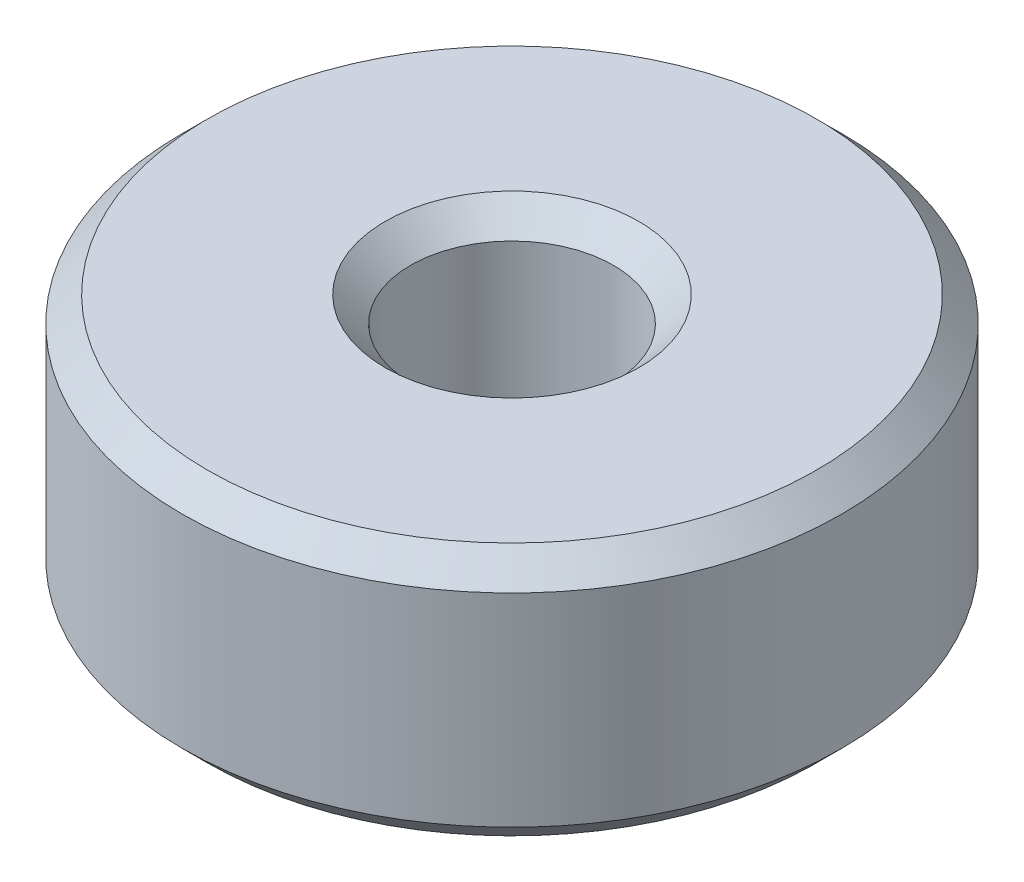
from build123d import *

# Parameters (mm, degrees)
SKETCH_1_R      = 6.5
SKETCH_1_R_2    = 2
EXTRUDE_1_DEPTH = 5
CHAMFER_1_SIZE  = 0.5


with BuildPart() as part:
    # 草图1 → 凸台-拉伸1 (new body)
    with BuildSketch(Plane(origin=(0, 0, 0), x_dir=(1, 0, 0), z_dir=(0, 1, 0))):
        Circle(SKETCH_1_R)
        Circle(SKETCH_1_R_2, mode=Mode.SUBTRACT)
    extrude(amount=EXTRUDE_1_DEPTH)

    # 倒角1
    chamfer_1_edges = [part.edges().sort_by_distance(p)[0] for p in [
        (-6.5, 0, 0),
        (-6.5, 5, 0),
        (-2, 0, 0),
        (-2, 5, 0),
    ]]
    chamfer(chamfer_1_edges, length=CHAMFER_1_SIZE)


solid = part.part
